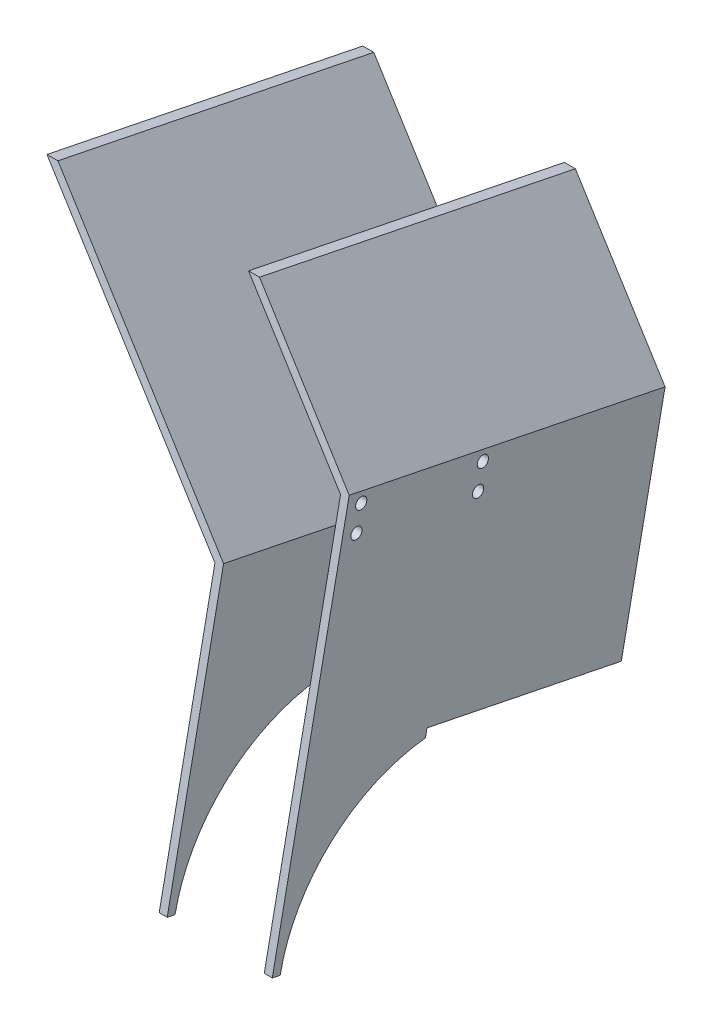
from build123d import *

# Parameters (mm, degrees)
BOSS_EXTRUDE1_DEPTH      = 55
BOSS_EXTRUDE1_DEPTH_BACK = 65.5
BOSS_EXTRUDE3_DEPTH      = 55
BOSS_EXTRUDE3_DEPTH_BACK = 65.5
BOSS_EXTRUDE5_DEPTH      = 3
BOSS_EXTRUDE6_DEPTH      = 3
SKETCH10_R               = 2.1
CUT_EXTRUDE1_DEPTH       = 3


with BuildPart() as part:
    # Sketch2 → Boss-Extrude1 (new body, two sides)
    with BuildSketch(Plane(origin=(0, 77.646629373, 383.211606662), x_dir=(0, 0.98008361, -0.198585292), z_dir=(0, -0.198585292, -0.98008361))) as boss_extrude1_sk:
        Polygon((1912.183265782, 36.994395038), (1826.61087511, 116.791940296), (1784.183265784, 116.791940296), (1784.183265784, 119.791940296), (1827.792606537, 119.791940296), (1912.183265782, 41.096377421), align=None)
    extrude(amount=BOSS_EXTRUDE1_DEPTH)
    extrude(boss_extrude1_sk.sketch, amount=-BOSS_EXTRUDE1_DEPTH_BACK)

    # Sketch8 → Boss-Extrude5 (add)
    with BuildSketch(Plane(origin=(119.791940296, 0, 0), x_dir=(0, 0, -1), z_dir=(1, 0, 0))):
        with BuildLine():
            Line((-93.094528353, 1839.302741325), (-47.64915541, 1830.094565037))
            Line((-47.64915541, 1830.094565037), (-48.244911285, 1827.154314208))
            ThreePointArc((-48.244911285, 1827.154314208), (-83.501130401, 1811.151044429), (-102.565858271, 1777.451759848))
            Line((-102.565858271, 1777.451759848), (-105.5061091, 1778.047515724))
            Line((-105.5061091, 1778.047515724), (-93.094528353, 1839.302741325))
        make_face()
    extrude(amount=-BOSS_EXTRUDE5_DEPTH)


with BuildPart() as body_2:
    # Sketch6 → Boss-Extrude3 (new body, two sides)
    with BuildSketch(Plane(origin=(0, 77.646629373, 383.211606662), x_dir=(0, 0.98008361, -0.198585292), z_dir=(0, -0.198585292, -0.98008361))) as boss_extrude3_sk:
        Polygon((1866.49410445, 159.080275109), (1912.183265782, 116.474442894), (1912.183265782, 112.37246051), (1865.312373023, 156.080275109), (1784.183265784, 156.080275109), (1784.183265784, 159.080275109), align=None)
    extrude(amount=BOSS_EXTRUDE3_DEPTH)
    extrude(boss_extrude3_sk.sketch, amount=-BOSS_EXTRUDE3_DEPTH_BACK)

    # Sketch9 → Boss-Extrude6 (add)
    with BuildSketch(Plane(origin=(159.080275109, 0, 0), x_dir=(0, 0, -1), z_dir=(1, 0, 0))):
        with BuildLine():
            Line((-93.094528353, 1839.302741325), (-47.64915541, 1830.094565037))
            Line((-47.64915541, 1830.094565037), (-48.244911285, 1827.154314208))
            ThreePointArc((-48.244911285, 1827.154314208), (-83.501130401, 1811.151044429), (-102.565858271, 1777.451759848))
            Line((-102.565858271, 1777.451759848), (-105.5061091, 1778.047515724))
            Line((-105.5061091, 1778.047515724), (-93.094528353, 1839.302741325))
        make_face()
    extrude(amount=-BOSS_EXTRUDE6_DEPTH)

    # Sketch10 → Cut-Extrude1 (cut)
    with BuildSketch(Plane(origin=(159.080275109, 0, 0), x_dir=(0, 0, -1), z_dir=(1, 0, 0))):
        with Locations((-28.563130495, 1897.139657439)):
            Circle(SKETCH10_R)
        with Locations((-26.775862867, 1905.960409926)):
            Circle(SKETCH10_R)
        with Locations((-72.250396343, 1915.174494743)):
            Circle(SKETCH10_R)
        with Locations((-74.03766397, 1906.353742257)):
            Circle(SKETCH10_R)
    extrude(amount=-CUT_EXTRUDE1_DEPTH, mode=Mode.SUBTRACT)


solid = Compound([part.part, body_2.part])
